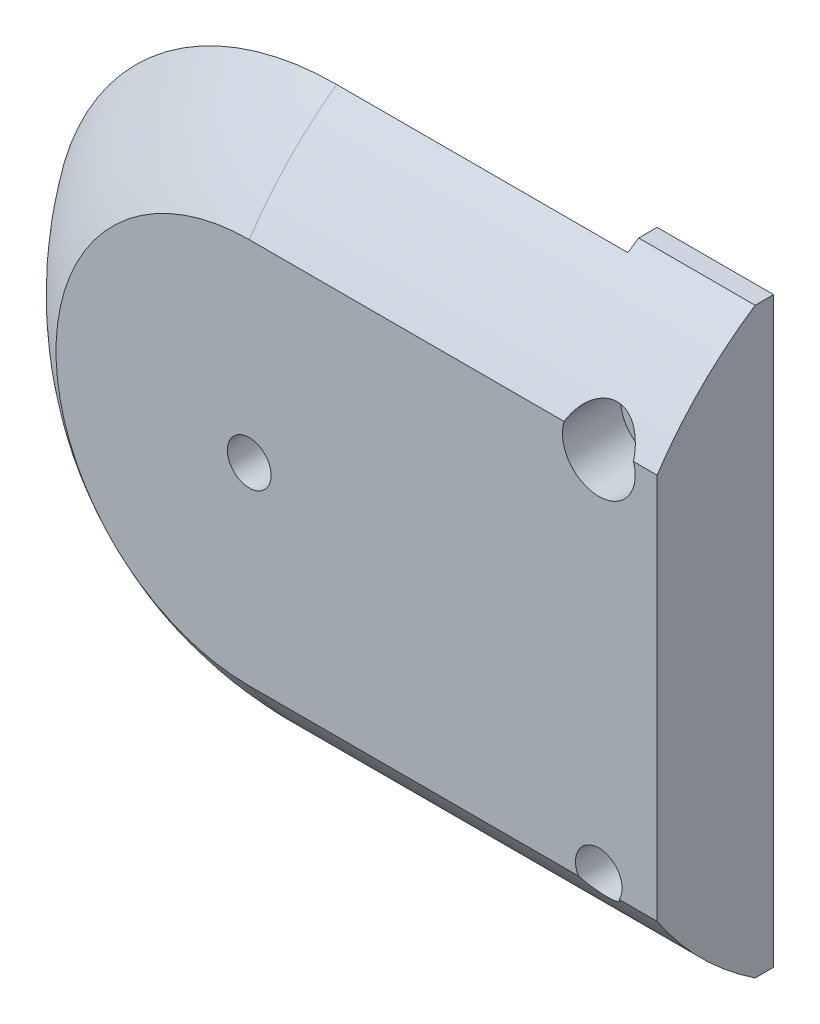
from build123d import *

# Parameters (mm, degrees)
SKETCH1_R           = 10
BOSS_EXTRUDE1_DEPTH = 4
BODY_START          = -3
SKETCH2_R           = 10
BODY_HOLE_DEPTH     = 2
BOSS_EXTRUDE2_START = -3
SKETCH11_R          = 2
BOSS_EXTRUDE2_DEPTH = 2
SKETCH4_R           = 0.75
CUT_EXTRUDE2_DEPTH  = 6
SKETCH3_R           = 0.8
SCREW_HOLES_DEPTH   = 6
SKETCH6_R           = 1.25
SCREW_HEADS_DEPTH   = 2
CUT_REVOLVE1_ANGLE  = 180
CUT_EXTRUDE1_DEPTH  = 15.000000004


with BuildPart() as part:
    # Sketch1 → Boss-Extrude1 (new body)
    with BuildSketch(Plane.XY):
        with Locations((4e-09, 0)):
            Circle(SKETCH1_R)
        with BuildLine():
            Line((14.000000004, 10), (4e-09, 10))
            ThreePointArc((4e-09, 10), (7.071067816, 7.071067812), (10.000000004, 0))
            ThreePointArc((10.000000004, 0), (7.071067816, -7.071067812), (4e-09, -10))
            Line((4e-09, -10), (14.000000004, -10))
            Line((14.000000004, -10), (14.000000004, 10))
        make_face()
    extrude(amount=-BOSS_EXTRUDE1_DEPTH)

    # Sketch2 → Body Hole (cut)
    with BuildSketch(Plane.XY.offset(BODY_START)):
        with Locations((4e-09, 0)):
            Circle(SKETCH2_R)
        with BuildLine():
            Line((10.000000004, 10), (4e-09, 10))
            ThreePointArc((4e-09, 10), (7.071067816, 7.071067812), (10.000000004, 0))
            Line((10.000000004, 0), (10.000000004, 10))
        make_face()
        with BuildLine():
            Line((10.000000004, -10), (10.000000004, 0))
            ThreePointArc((10.000000004, 0), (7.071067814, -7.071067813), (0, -10))
            Line((0, -10), (10.000000004, -10))
        make_face()
    extrude(amount=-BODY_HOLE_DEPTH, mode=Mode.SUBTRACT)

    # Sketch11 → Boss-Extrude2 (add)
    with BuildSketch(Plane.XY.offset(BOSS_EXTRUDE2_START)):
        with Locations((4e-09, 0)):
            Circle(SKETCH11_R)
    extrude(amount=-BOSS_EXTRUDE2_DEPTH)

    # Sketch4 → Cut-Extrude2 (cut, through all)
    with BuildSketch(Plane.XY):
        with Locations((4e-09, 0)):
            Circle(SKETCH4_R)
    extrude(amount=-CUT_EXTRUDE2_DEPTH, mode=Mode.SUBTRACT)

    # Sketch3 → Screw Holes (cut, through all)
    with BuildSketch(Plane.XY):
        with Locations((12.000000004, 6.25)):
            Circle(SKETCH3_R)
        with Locations((12.000000004, -6.25)):
            Circle(SKETCH3_R)
    extrude(amount=-SCREW_HOLES_DEPTH, mode=Mode.SUBTRACT)

    # Sketch6 → Screw Heads (cut)
    with BuildSketch(Plane.XY):
        with Locations((12.000000004, 6.25)):
            Circle(SKETCH6_R)
    extrude(amount=-SCREW_HEADS_DEPTH, mode=Mode.SUBTRACT)

    # Sketch9 → Cut-Revolve1 (revolve, cut)
    with BuildSketch(Plane(origin=(0, 0, 0), x_dir=(0, 0, -1), z_dir=(1, 0, 0))):
        with BuildLine():
            Line((-2, 12), (-2, 2.75))
            Line((-2, 2.75), (-1.680646386, 2.75))
            ThreePointArc((-1.680646386, 2.75), (2.550167787, 9.407443861), (10, 12))
            Line((10, 12), (-2, 12))
        make_face()
    revolve(axis=Axis((0, 0, 0), (0, 0, 1)), revolution_arc=CUT_REVOLVE1_ANGLE, mode=Mode.SUBTRACT)

    # Sketch10 → Cut-Extrude1 (cut, through all)
    with BuildSketch(Plane(origin=(0, 0, 0), x_dir=(0, 0, -1), z_dir=(1, 0, 0))):
        with BuildLine():
            ThreePointArc((10, 12), (1.514718626, 8.485281374), (-2, 0))
            Line((-2, 0), (-2, 12))
            Line((-2, 12), (10, 12))
        make_face()
        with BuildLine():
            ThreePointArc((-2, 0), (1.514718626, -8.485281374), (10, -12))
            Line((10, -12), (-2, -12))
            Line((-2, -12), (-2, 0))
        make_face()
    extrude(amount=CUT_EXTRUDE1_DEPTH, mode=Mode.SUBTRACT)


solid = part.part
